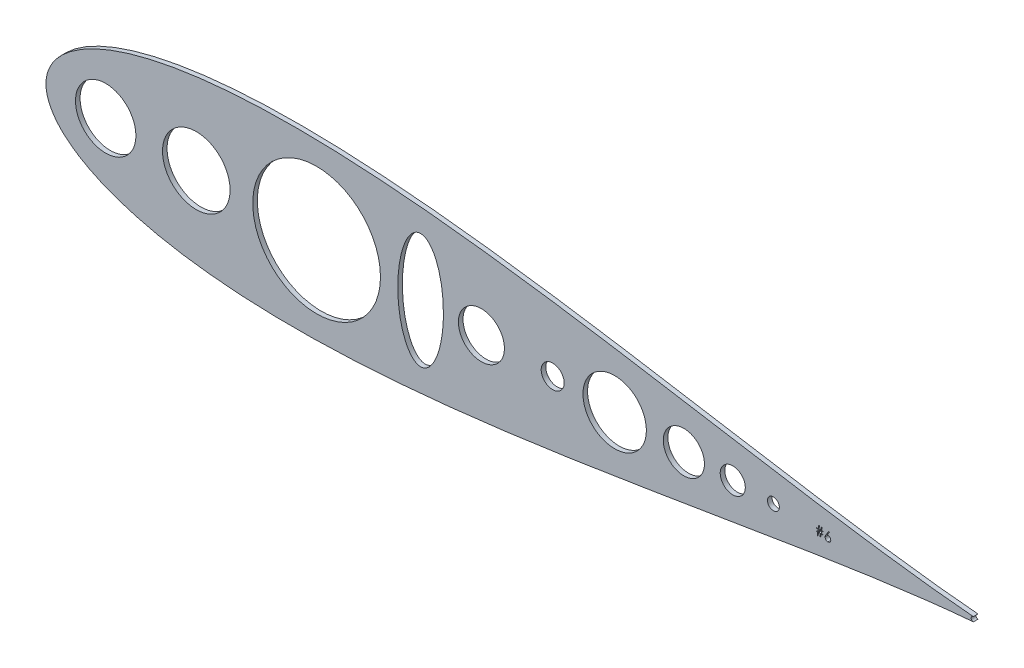
from build123d import *

# Parameters (mm, degrees)
SKETCH2_R           = 16.684756317
SKETCH2_R_2         = 3.290720854
SKETCH2_R_3         = 6.929178572
SKETCH2_R_4         = 11.353225487
SKETCH2_R_5         = 12.7
SKETCH2_R_6         = 18.669
SKETCH2_R_7         = 35.269562724
SKETCH2_R_8         = 17.51105103
SKETCH2_R_9         = 6.35
SKETCH2_RX          = 31.857226633
SKETCH2_RY          = 12.621591574
BOSS_EXTRUDE1_DEPTH = 2.54


with BuildPart() as part:
    # Sketch2 → Boss-Extrude1 (new body)
    with BuildSketch(Plane.XY):
        with BuildLine():
            ThreePointArc((807.167977043, 506.107856593), (807.230735315, 506.114655719), (807.293076359, 506.124576558))
            ThreePointArc((807.293076359, 506.124576558), (806.050818396, 507.370050345), (807.296292183, 508.612308308))
            ThreePointArc((807.296292183, 508.612308308), (807.232356297, 508.622610098), (807.167977043, 508.629626938))
            add(Edge.make_bspline(
                [(807.167977043, 508.629626938), (806.75556387, 508.66392306), (803.647531721, 508.925718255), (797.52664268, 509.491460006), (788.441087145, 510.436596938), (778.367696007, 511.596371668), (767.344336409, 512.977736789), (755.422437077, 514.582098777), (742.653553938, 516.405860709), (729.09298087, 518.439602072), (714.798302658, 520.668855208), (699.829405642, 523.073715763), (684.248150263, 525.629344831), (668.118191248, 528.306279308), (651.504771353, 531.070730691), (634.474612041, 533.885190092), (617.095803744, 536.708878542), (599.437748459, 539.498415452), (581.571122135, 542.208403286), (563.567871851, 544.792233391), (545.501207393, 547.202677352), (527.445619023, 549.392728793), (509.476889849, 551.316278974), (491.672107407, 552.928931019), (474.109656298, 554.188647551), (456.869216665, 555.056536763), (440.031746858, 555.497584163), (423.679455897, 555.481209943), (407.895831124, 554.98143874), (392.765639508, 553.978702977), (378.375173965, 552.458462002), (364.812390016, 550.413863121), (352.167727941, 547.844189114), (340.534726814, 544.758038591), (330.011732264, 541.173498728), (320.703721418, 537.122508379), (312.723728741, 532.658711673), (306.190971712, 527.872692216), (301.215454505, 522.92076825), (297.846949829, 518.064764241), (295.968577745, 513.683683147), (295.210055594, 510.16923767), (295.03729534, 507.368741768), (295.210055594, 504.568245866), (295.968577745, 501.053800388), (297.846949829, 496.672719294), (301.215454505, 491.816715285), (306.190971712, 486.864791319), (312.723728741, 482.078771863), (320.703721418, 477.614975157), (330.011732264, 473.563984807), (340.534726814, 469.979444944), (352.167727941, 466.893294421), (364.812390016, 464.323620414), (378.375173965, 462.279021534), (392.765639508, 460.758780559), (407.895831124, 459.756044796), (423.679455897, 459.256273592), (440.031746858, 459.239899372), (456.869216665, 459.680946773), (474.109656298, 460.548835985), (491.672107407, 461.808552516), (509.476889849, 463.421204561), (527.445619023, 465.344754743), (545.501207393, 467.534806183), (563.567871851, 469.945250145), (581.571122135, 472.52908025), (599.437748459, 475.239068083), (617.095803744, 478.028604993), (634.474612041, 480.852293444), (651.504771353, 483.666752844), (668.118191248, 486.431204228), (684.248150263, 489.108138705), (699.829405642, 491.663767772), (714.798302658, 494.068628328), (729.09298087, 496.297881464), (742.653553938, 498.331622827), (755.422437077, 500.155384759), (767.344336409, 501.759746747), (778.367696007, 503.141111868), (788.441087145, 504.300886597), (797.52664268, 505.24602353), (803.647531721, 505.811765281), (806.75556387, 506.073560475), (807.167977043, 506.107856593)],
                knots=[0.020157042, 0.020157042, 0.020157042, 0.020157042, 0.021270888, 0.028552555, 0.036780684, 0.045920102, 0.055931764, 0.066772884, 0.07839713, 0.090754827, 0.103793165, 0.117456432, 0.131686226, 0.146421738, 0.161599998, 0.177156133, 0.193023668, 0.209134786, 0.225420633, 0.241811602, 0.258237647, 0.274628557, 0.290914287, 0.307025229, 0.322892517, 0.338448342, 0.353626207, 0.368361232, 0.382590428, 0.396252961, 0.409290412, 0.42164701, 0.433269881, 0.444109249, 0.45411864, 0.463255055, 0.471479114, 0.478755289, 0.485052318, 0.490344026, 0.494609833, 0.497833231, 0.5, 0.502166769, 0.505390167, 0.509655974, 0.514947682, 0.521244711, 0.528520886, 0.536744945, 0.54588136, 0.555890751, 0.566730119, 0.57835299, 0.590709588, 0.603747039, 0.617409572, 0.631638768, 0.646373793, 0.661551658, 0.677107483, 0.692974771, 0.709085713, 0.725371443, 0.741762353, 0.758188398, 0.774579367, 0.790865214, 0.806976332, 0.822843867, 0.838400002, 0.853578262, 0.868313774, 0.882543568, 0.896206835, 0.909245173, 0.92160287, 0.933227116, 0.944068236, 0.954079898, 0.963219316, 0.971447445, 0.978729112, 0.979842958, 0.979842958, 0.979842958, 0.979842958], degree=3))
        make_face()
        with Locations((328.059630077, 507.368741765)):
            Circle(SKETCH2_R, mode=Mode.SUBTRACT)
        with Locations((696.832666428, 507.368741765)):
            Circle(SKETCH2_R_2, mode=Mode.SUBTRACT)
        with Locations((674.39067116, 507.368741765)):
            Circle(SKETCH2_R_3, mode=Mode.SUBTRACT)
        with Locations((647.386638422, 507.368741765)):
            Circle(SKETCH2_R_4, mode=Mode.SUBTRACT)
        with Locations((535.566410166, 507.368741765)):
            Circle(SKETCH2_R_5, mode=Mode.SUBTRACT)
        with Locations((378.086410166, 507.368741765)):
            Circle(SKETCH2_R_6, mode=Mode.SUBTRACT)
        with Locations((444.548784388, 507.368741765)):
            Circle(SKETCH2_R_7, mode=Mode.SUBTRACT)
        with Locations((609.164810502, 507.368741765)):
            Circle(SKETCH2_R_8, mode=Mode.SUBTRACT)
        with Locations((574.936410166, 507.368741765)):
            Circle(SKETCH2_R_9, mode=Mode.SUBTRACT)
        with Locations(Location((501.997685248, 507.368741765), (0, 0, 90))):
            Ellipse(SKETCH2_RX, SKETCH2_RY, mode=Mode.SUBTRACT)
        with BuildLine():
            Line((727.833075314, 509.263570782), (726.490823713, 507.211014695))
            add(Edge.make_bspline(
                [(726.490823713, 507.211014695), (726.580188568, 507.225258813), (726.75450483, 507.253043575), (726.930949048, 507.257627108), (727.01693749, 507.259860849)],
                knots=[0, 0, 0, 0, 0.512659336, 1, 1, 1, 1], degree=3))
            add(Edge.make_bspline(
                [(727.01693749, 507.259860849), (727.068568428, 507.258473121), (727.170202392, 507.25574142), (727.319419122, 507.234719146), (727.462804206, 507.201590126), (727.599763346, 507.153297823), (727.730788132, 507.091608692), (727.856630466, 507.01767456), (727.974924813, 506.927677744), (728.087194524, 506.827144608), (728.18912414, 506.715795385), (728.279368243, 506.597647159), (728.355171701, 506.472823023), (728.416674421, 506.341386201), (728.464433502, 506.203539298), (728.499249856, 506.059458684), (728.519830522, 505.909045006), (728.522625234, 505.806750969), (728.524044862, 505.754788734)],
                knots=[0, 0, 0, 0, 0.065230804, 0.128404896, 0.190067072, 0.250943366, 0.311545833, 0.372862802, 0.435023674, 0.499071725, 0.563091075, 0.625510106, 0.686680036, 0.747282503, 0.808563495, 0.870742104, 0.934340952, 1, 1, 1, 1], degree=3))
            add(Edge.make_bspline(
                [(728.524044862, 505.754788734), (728.521979327, 505.683698192), (728.517914843, 505.54380883), (728.477414476, 505.340062068), (728.414481049, 505.145958874), (728.324525093, 504.964598271), (728.212790663, 504.796228827), (728.076534043, 504.647043066), (727.920587494, 504.513990554), (727.744258084, 504.402728947), (727.554494011, 504.31186509), (727.355137397, 504.246601253), (727.148124282, 504.206420675), (727.007619308, 504.201383343), (726.936544862, 504.198835208)],
                knots=[0, 0, 0, 0, 0.085947943, 0.169125212, 0.250399107, 0.332289736, 0.413364288, 0.494172283, 0.576021735, 0.660756969, 0.745783126, 0.830043593, 0.914027546, 1, 1, 1, 1], degree=3))
            add(Edge.make_bspline(
                [(726.936544862, 504.198835208), (726.868187365, 504.20105329), (726.732783132, 504.205446921), (726.533599534, 504.244586053), (726.342209783, 504.308023791), (726.159954796, 504.395420515), (725.991123735, 504.5058131), (725.840079897, 504.638709208), (725.707576407, 504.791268089), (725.597304671, 504.963466078), (725.509843426, 505.148508645), (725.444253478, 505.341457432), (725.405941216, 505.541609406), (725.400587539, 505.677290602), (725.397891016, 505.74563008)],
                knots=[0, 0, 0, 0, 0.084334722, 0.167052318, 0.249566077, 0.332740482, 0.415914886, 0.49782801, 0.580372589, 0.664600121, 0.749466693, 0.832510234, 0.915639282, 1, 1, 1, 1], degree=3))
            add(Edge.make_bspline(
                [(725.397891016, 505.74563008), (725.399605799, 505.797946218), (725.403107058, 505.904765776), (725.427554036, 506.066547851), (725.466836653, 506.232084849), (725.51082981, 506.37251665), (725.557312696, 506.487559088), (725.595996953, 506.58031044), (725.644146639, 506.67575794), (725.695488575, 506.777174532), (725.754644259, 506.881946532), (725.818965259, 506.991825), (725.890229895, 507.10506245), (725.940188303, 507.181907167), (725.965727553, 507.221190981)],
                knots=[0, 0, 0, 0, 0.09781819, 0.199726053, 0.305276357, 0.415811491, 0.474472231, 0.53727388, 0.603657421, 0.674298863, 0.749834485, 0.828598477, 0.912377778, 1, 1, 1, 1], degree=3))
            Line((725.965727553, 507.221190981), (727.481993578, 509.539348031))
            Line((727.481993578, 509.539348031), (727.833075314, 509.263570782))
        make_face(mode=Mode.SUBTRACT)
        Polygon((724.290711527, 507.58550187), (723.413516015, 507.58550187), (723.238483965, 506.413194182), (724.160455115, 506.413194182), (724.160455115, 506.087553157), (723.189637814, 506.087553157), (722.926072103, 504.329091619), (722.53224999, 504.329091619), (722.795815691, 506.087553157), (721.756817301, 506.087553157), (721.49325159, 504.329091619), (721.099429477, 504.329091619), (721.362995178, 506.087553157), (720.513275628, 506.087553157), (720.513275628, 506.413194182), (721.411841339, 506.413194182), (721.587891015, 507.58550187), (720.64353204, 507.58550187), (720.64353204, 507.911142896), (721.636737166, 507.911142896), (721.88096794, 509.539348031), (722.273772427, 509.539348031), (722.029541653, 507.911142896), (723.069557678, 507.911142896), (723.313788452, 509.539348031), (723.70659294, 509.539348031), (723.462362166, 507.911142896), (724.290711527, 507.911142896), align=None, mode=Mode.SUBTRACT)
    extrude(amount=BOSS_EXTRUDE1_DEPTH)


solid = part.part
